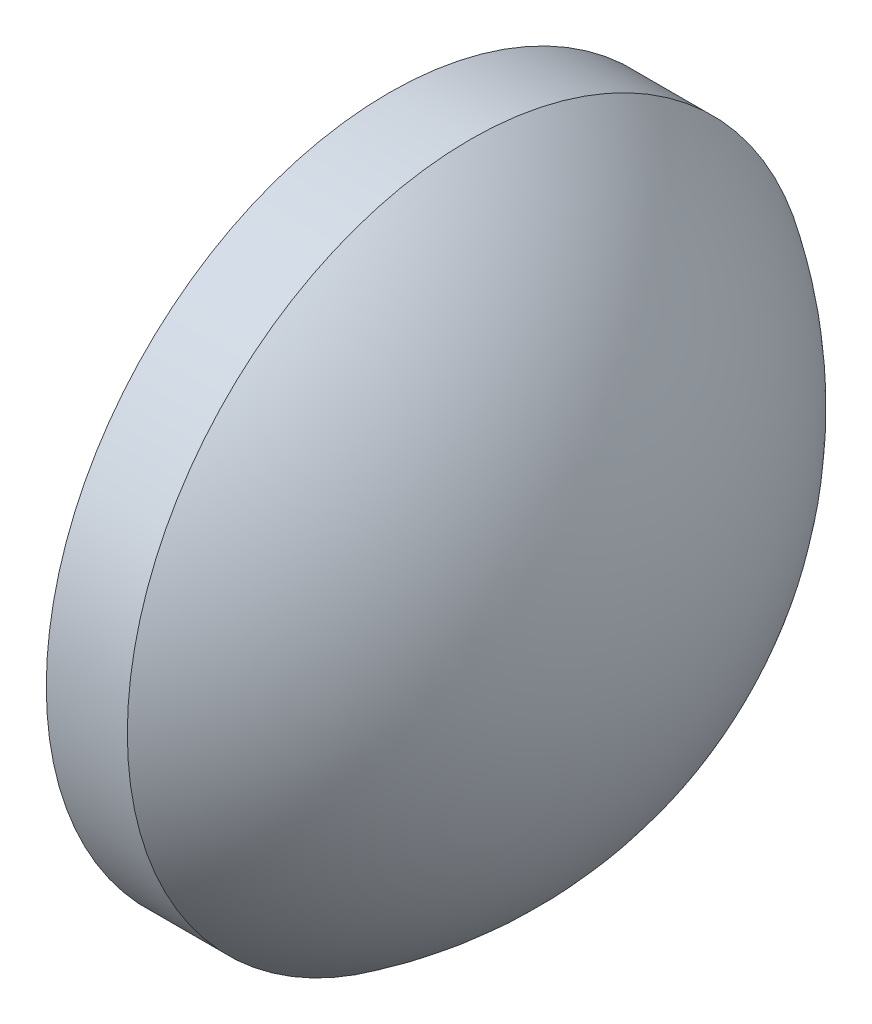
from build123d import *


with BuildPart() as part:
    # 草图1 → 旋转1 (revolve)
    with BuildSketch(Plane.XY):
        with BuildLine():
            Line((115.773606431, 65.233554926), (115.773606431, 77.933554926))
            Line((115.773606431, 77.933554926), (118.775483802, 77.933554926))
            ThreePointArc((118.775483802, 77.933554926), (123.844825536, 72.462181322), (125.683606431, 65.233554926))
            Line((125.683606431, 65.233554926), (115.773606431, 65.233554926))
        make_face()
    revolve(axis=Axis((110.165373228, 65.233554926, 0), (1, 0, 0)))


solid = part.part
